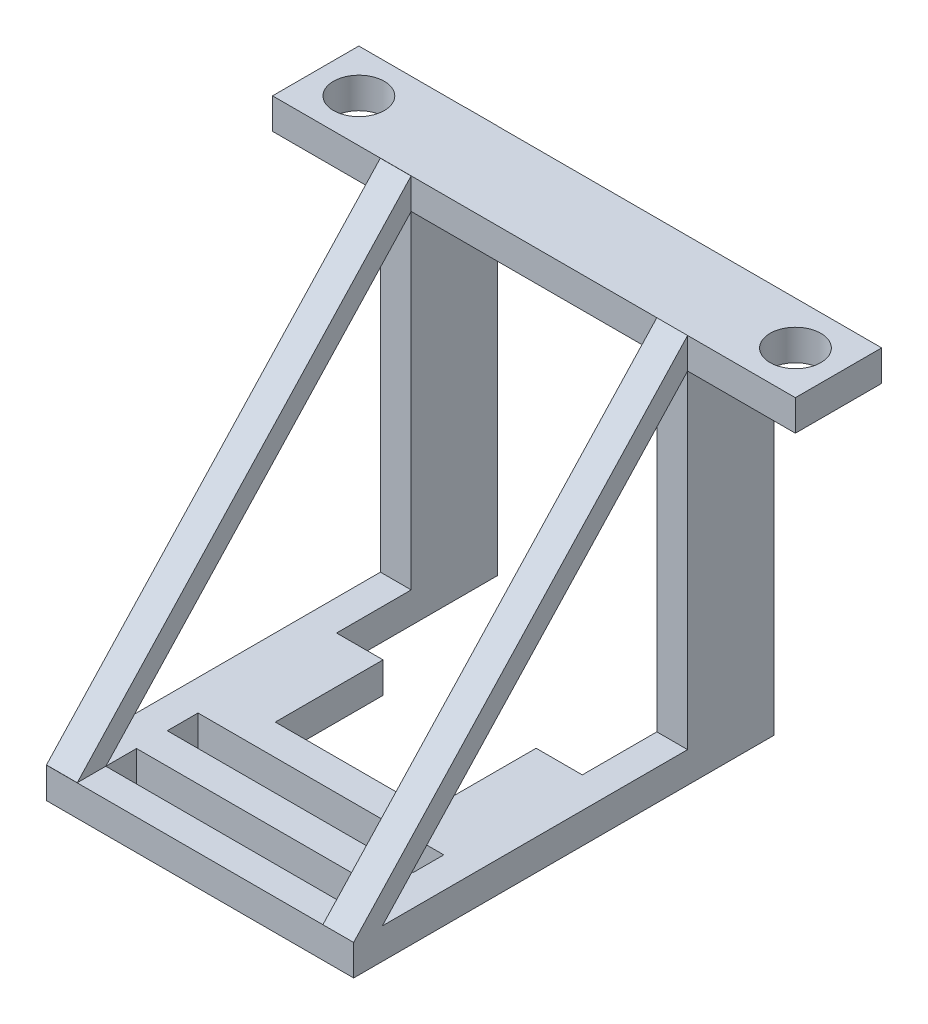
from build123d import *

# Parameters (mm, degrees)
SKETCH1_W           = 16.981866596
SKETCH1_H           = 2.802651254
SKETCH1_R           = 0.825
BOSS_EXTRUDE1_DEPTH = 1
BOSS_EXTRUDE4_DEPTH = 1
BOSS_EXTRUDE5_DEPTH = 1
SKETCH15_W          = 0.931061544
SKETCH15_H          = 1
SKETCH15_W_2        = 0.998936147
BOSS_EXTRUDE6_DEPTH = 9.981867
SKETCH16_W          = 1.5
SKETCH16_H          = 3.5
SKETCH16_W_2        = 1.510044564
BOSS_EXTRUDE7_DEPTH = 1


with BuildPart() as part:
    # Sketch1 → Boss-Extrude1 (new body)
    with BuildSketch(Plane(origin=(0, 0, 0), x_dir=(1, 0, 0), z_dir=(0, 1, 0))):
        with Locations((-27.477281267, 0.001515376)):
            Rectangle(SKETCH1_W, SKETCH1_H)
        with Locations((-34.563340606, 0)):
            Circle(SKETCH1_R, mode=Mode.SUBTRACT)
        with Locations((-20.383340606, 0)):
            Circle(SKETCH1_R, mode=Mode.SUBTRACT)
    extrude(amount=BOSS_EXTRUDE1_DEPTH)

    # Sketch9 → Boss-Extrude4 (add)
    with BuildSketch(Plane(origin=(-23.486347969, 0, 0), x_dir=(0, 0, -1), z_dir=(1, 0, 0))):
        Polygon((1.402841003, 1), (1.402841003, -11.65), (-12.246677238, -11.65), (-12.246677238, -10.65), (-1.399810251, 1), align=None)
        Polygon((-1.399810251, 0), (-11.315615694, -10.65), (-1.399810251, -10.65), align=None, mode=Mode.SUBTRACT)
    extrude(amount=BOSS_EXTRUDE4_DEPTH)

    # Sketch14 → Boss-Extrude5 (add)
    with BuildSketch(Plane.ZY.offset(31.468214565)):
        Polygon((-1.406908915, 1), (-1.406908915, -11.65), (12.242609326, -11.65), (12.242609326, -10.65), (1.395742339, 1), align=None)
        Polygon((11.311547782, -10.65), (1.395742339, -10.65), (1.395742339, 0), align=None, mode=Mode.SUBTRACT)
    extrude(amount=BOSS_EXTRUDE5_DEPTH)

    # Sketch15 → Boss-Extrude6 (add)
    with BuildSketch(Plane(origin=(-22.486347969, 0, 0), x_dir=(0, 0, -1), z_dir=(1, 0, 0))):
        with Locations((-11.781146466, -11.15)):
            Rectangle(SKETCH15_W, SKETCH15_H)
        with Locations((-9.817677681, -11.15)):
            Rectangle(SKETCH15_W_2, SKETCH15_H)
        with Locations((-7.819805388, -11.15)):
            Rectangle(SKETCH15_W_2, SKETCH15_H)
    extrude(amount=-BOSS_EXTRUDE6_DEPTH)

    # Sketch16 → Boss-Extrude7 (add)
    with BuildSketch(Plane.XZ.offset(11.65)):
        with Locations((-24.236347969, 5.570337314)):
            Rectangle(SKETCH16_W, SKETCH16_H)
        with Locations((-30.713192283, 5.570337314)):
            Rectangle(SKETCH16_W_2, SKETCH16_H)
    extrude(amount=-BOSS_EXTRUDE7_DEPTH)


solid = part.part
